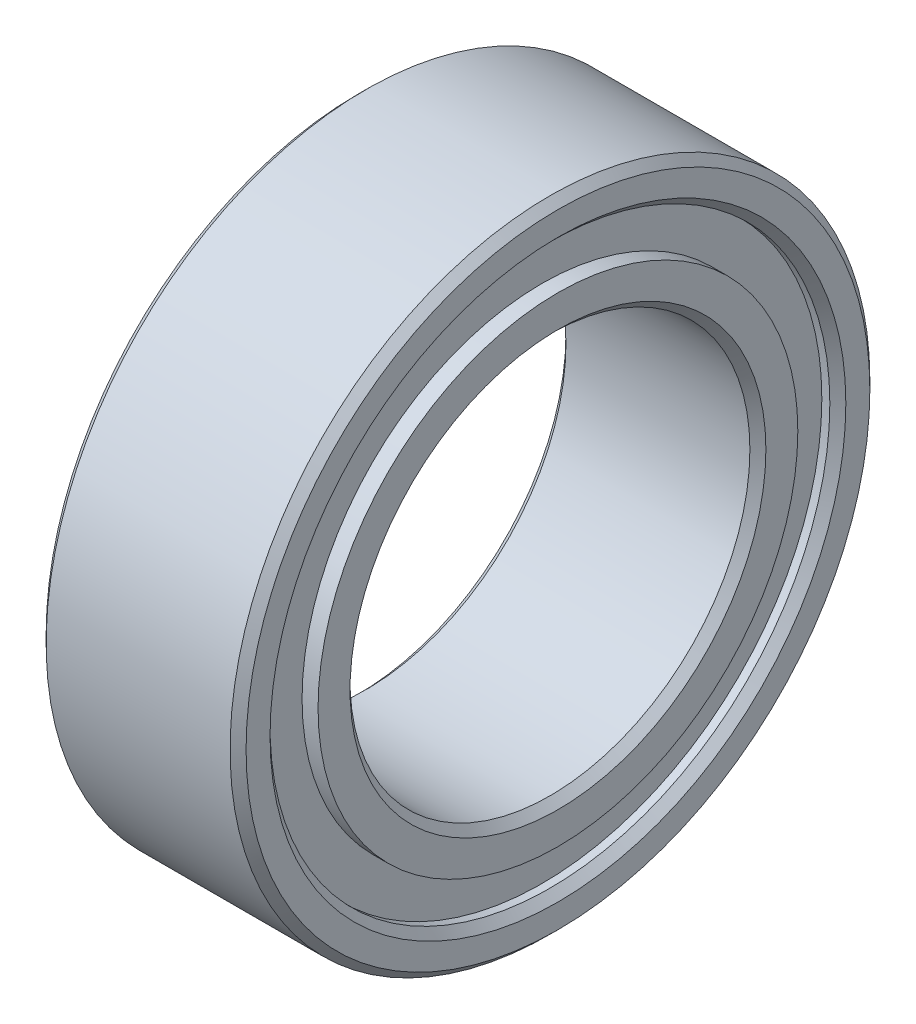
from build123d import *

# Parameters (mm, degrees)
SKETCH_1_R          = 4
SKETCH_1_R_2        = 2.5
EXTRUDE_1_DEPTH     = 2.5
SKETCH_2_R          = 3.5
SKETCH_2_R_2        = 2.999624375
CUT_EXTRUDE_1_DEPTH = 0.2
SKETCH_3_R          = 3.5
SKETCH_3_R_2        = 2.950876812
CUT_EXTRUDE_2_DEPTH = 0.2
CHAMFER_1_SIZE      = 0.1


with BuildPart() as part:
    # 草图1 → 凸台-拉伸1 (new body)
    with BuildSketch(Plane(origin=(0, 0, 0), x_dir=(0, 0, -1), z_dir=(1, 0, 0))):
        Circle(SKETCH_1_R)
        Circle(SKETCH_1_R_2, mode=Mode.SUBTRACT)
    extrude(amount=EXTRUDE_1_DEPTH)

    # 草图2 → 切除-拉伸1 (cut)
    with BuildSketch(Plane(origin=(2.5, 0, 0), x_dir=(0, 0, -1), z_dir=(1, 0, 0))):
        with Locations((-0.000375625, 0)):
            Circle(SKETCH_2_R)
        with Locations((-0.000375625, 0)):
            Circle(SKETCH_2_R_2, mode=Mode.SUBTRACT)
    extrude(amount=-CUT_EXTRUDE_1_DEPTH, mode=Mode.SUBTRACT)

    # 草图3 → 切除-拉伸2 (cut)
    with BuildSketch(Plane.ZY):
        with Locations((-0.049123188, 0)):
            Circle(SKETCH_3_R)
        with Locations((-0.049123188, 0)):
            Circle(SKETCH_3_R_2, mode=Mode.SUBTRACT)
    extrude(amount=-CUT_EXTRUDE_2_DEPTH, mode=Mode.SUBTRACT)

    # 倒角1
    chamfer_1_edges = [part.edges().sort_by_distance(p)[0] for p in [
        (2.5, 0, 3.500375625),
        (0, 0, 4),
        (0, 0, -3.549123188),
        (0, 0, -3),
        (2.5, 0, 4),
        (0, 0, 2.5),
        (2.5, 0, 2.5),
    ]]
    chamfer(chamfer_1_edges, length=CHAMFER_1_SIZE)


solid = part.part
